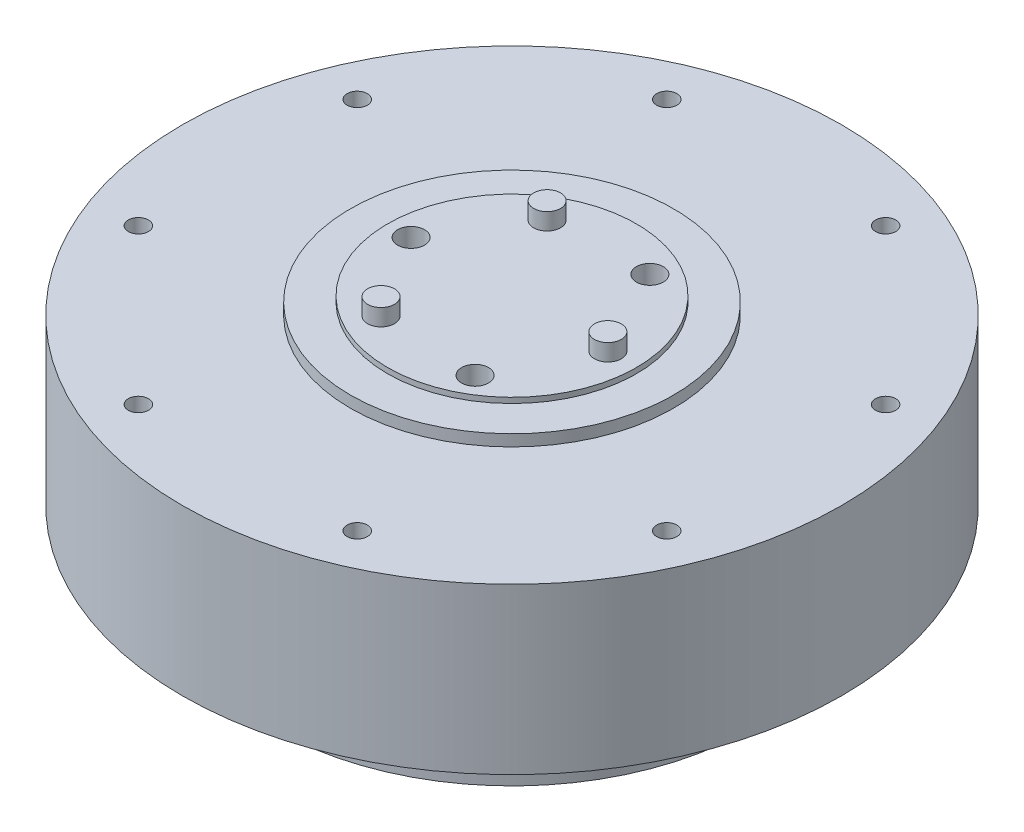
from build123d import *

# Parameters (mm, degrees)
SKETCH1_R           = 49
BOSS_EXTRUDE1_DEPTH = 24.5
SKETCH2_R           = 24
BOSS_EXTRUDE2_DEPTH = 1.7
SKETCH3_R           = 18.5
BOSS_EXTRUDE3_DEPTH = 0.8
SKETCH4_R           = 35.5
BOSS_EXTRUDE4_DEPTH = 11
CIRPATTERN1_COUNT   = 8
CIRPATTERN2_COUNT   = 6
CUT_EXTRUDE1_START  = -3.5
SKETCH20_R          = 1.5
CUT_EXTRUDE1_DEPTH  = 3.5
SKETCH21_R          = 2
BOSS_EXTRUDE5_DEPTH = 2.5
CIRPATTERN3_COUNT   = 3


with BuildPart() as part:
    # Sketch1 → Boss-Extrude1 (new body)
    with BuildSketch(Plane(origin=(0, 0, 0), x_dir=(1, 0, 0), z_dir=(0, 1, 0))):
        Circle(SKETCH1_R)
    extrude(amount=BOSS_EXTRUDE1_DEPTH)

    # Sketch2 → Boss-Extrude2 (add)
    with BuildSketch(Plane(origin=(0, 24.5, 0), x_dir=(1, 0, 0), z_dir=(0, 1, 0))):
        Circle(SKETCH2_R)
    extrude(amount=BOSS_EXTRUDE2_DEPTH)

    # Sketch3 → Boss-Extrude3 (add)
    with BuildSketch(Plane(origin=(0, 26.2, 0), x_dir=(1, 0, 0), z_dir=(0, 1, 0))):
        Circle(SKETCH3_R)
    extrude(amount=BOSS_EXTRUDE3_DEPTH)

    # Sketch4 → Boss-Extrude4 (add)
    with BuildSketch(Plane.XZ):
        Circle(SKETCH4_R)
    extrude(amount=BOSS_EXTRUDE4_DEPTH)

    # Sketch13 → Ø3.0mm Dowel Hole1 (revolve, cut)
    with BuildSketch(Plane(origin=(-39.264880132, 0, 16.264045876), x_dir=(0, 0, -1), z_dir=(1, 0, 0))):
        Polygon((0, 0), (0, 3.901290929), (1.5, 3), (1.5, 0), align=None)
    f_3_0mm_dowel_hole1 = revolve(axis=Axis((-39.264880132, -6.35, 16.264045876), (0, 1, 0)), mode=Mode.SUBTRACT)

    # CirPattern1: Ø3.0mm Dowel Hole1 ×8 about axis
    cirpattern1_axis = Axis((0, -12.925, 0), (0, 1, 0))
    for i in range(1, CIRPATTERN1_COUNT):
        add(f_3_0mm_dowel_hole1.rotate(cirpattern1_axis, i * 360 / CIRPATTERN1_COUNT), mode=Mode.SUBTRACT)

    # Sketch15 → Ø4.0mm Dowel Hole1 (revolve, cut)
    with BuildSketch(Plane(origin=(-15, 27, 0), x_dir=(0, 0, 1), z_dir=(1, 0, 0))):
        Polygon((0, 0), (0, 5.701721238), (2, 4.5), (2, 0), align=None)
    f_4_0mm_dowel_hole1 = revolve(axis=Axis((-15, 33.35, 0), (0, -1, 0)), mode=Mode.SUBTRACT)

    # CirPattern2: Ø4.0mm Dowel Hole1 ×6 about axis, 3 skipped
    cirpattern2_axis = Axis((0, -12.925, 0), (0, 1, 0))
    add([f_4_0mm_dowel_hole1.rotate(cirpattern2_axis, i * 360 / CIRPATTERN2_COUNT) for i in range(1, CIRPATTERN2_COUNT) if i not in (1, 3, 5)], mode=Mode.SUBTRACT)

    # Sketch20 → Cut-Extrude1 (cut)
    with BuildSketch(Plane(origin=(0, 24.5, 0), x_dir=(1, 0, 0), z_dir=(0, 1, 0)).offset(CUT_EXTRUDE1_START)):
        with Locations((39.264880132, -16.264045876)):
            Circle(SKETCH20_R)
        with Locations((16.264045876, -39.264880132)):
            Circle(SKETCH20_R)
        with Locations((-16.264045876, -39.264880132)):
            Circle(SKETCH20_R)
        with Locations((-39.264880132, -16.264045876)):
            Circle(SKETCH20_R)
        with Locations((-39.264880132, 16.264045876)):
            Circle(SKETCH20_R)
        with Locations((-16.264045876, 39.264880132)):
            Circle(SKETCH20_R)
        with Locations((16.264045876, 39.264880132)):
            Circle(SKETCH20_R)
        with Locations((39.264880132, 16.264045876)):
            Circle(SKETCH20_R)
    extrude(amount=CUT_EXTRUDE1_DEPTH, mode=Mode.SUBTRACT)

    # Sketch21 → Boss-Extrude5 (add)
    with BuildSketch(Plane(origin=(0, 27, 0), x_dir=(1, 0, 0), z_dir=(0, 1, 0))):
        with Locations((-7.125, 12.340862004)):
            Circle(SKETCH21_R)
    boss_extrude5 = extrude(amount=BOSS_EXTRUDE5_DEPTH)

    # CirPattern3: Boss-Extrude5 ×3 about axis
    cirpattern3_axis = Axis((0, 27, 0), (0, 1, 0))
    for i in range(1, CIRPATTERN3_COUNT):
        add(boss_extrude5.rotate(cirpattern3_axis, i * 360 / CIRPATTERN3_COUNT))


solid = part.part
